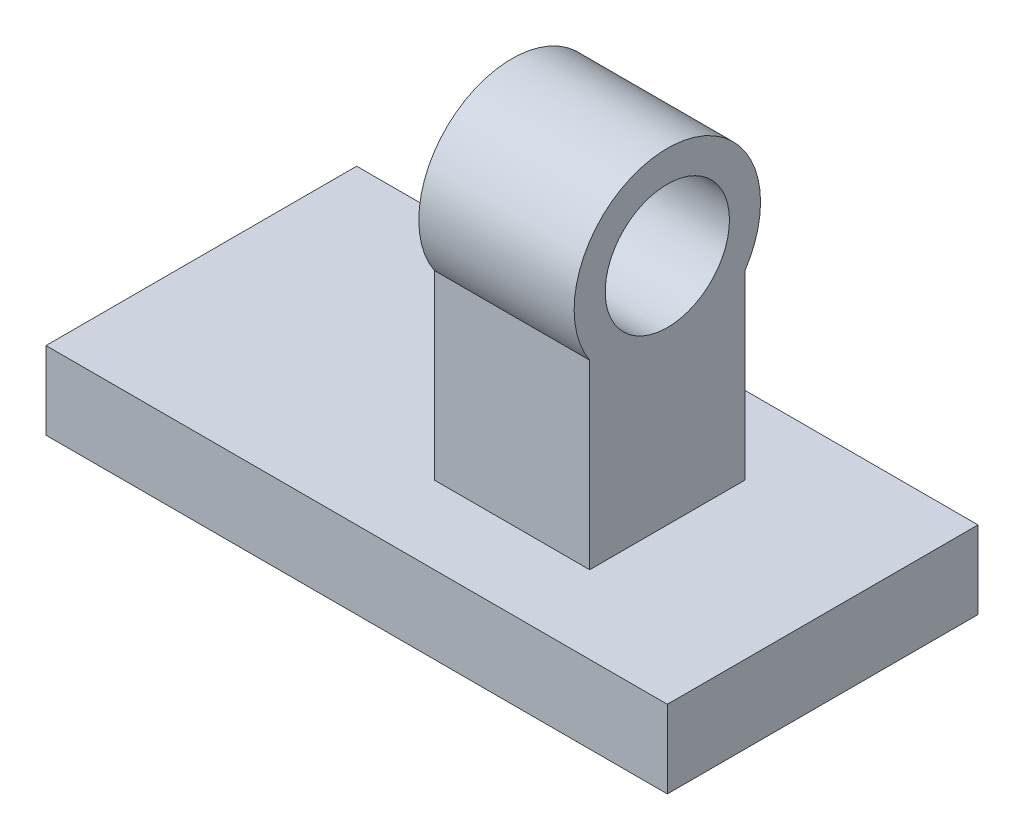
from build123d import *

# Parameters (mm, degrees)
LINKFRAME_R         = 40
BOSS_EXTRUDE1_DEPTH = 100
EXTENDEDPRESS_W     = 200
EXTENDEDPRESS_H     = 50
BOSS_EXTRUDE2_DEPTH = 200


with BuildPart() as part:
    # LinkFrame → Boss-Extrude1 (new body)
    with BuildSketch(Plane(origin=(0, 0, 0), x_dir=(0, 0, -1), z_dir=(1, 0, 0))):
        with BuildLine():
            Line((316.746524862, -249.209808828), (316.746524862, -366.043560924))
            Line((316.746524862, -366.043560924), (366.746524862, -366.043560924))
            Line((366.746524862, -366.043560924), (366.746524862, -416.043560924))
            Line((366.746524862, -416.043560924), (166.746524862, -416.043560924))
            Line((166.746524862, -416.043560924), (166.746524862, -366.043560924))
            Line((166.746524862, -366.043560924), (216.746524862, -366.043560924))
            Line((216.746524862, -366.043560924), (216.746524862, -249.209808828))
            ThreePointArc((216.746524862, -249.209808828), (266.746524862, -156.043560924), (316.746524862, -249.209808828))
        make_face()
        with Locations((266.746524862, -216.043560924)):
            Circle(LINKFRAME_R, mode=Mode.SUBTRACT)
    extrude(amount=BOSS_EXTRUDE1_DEPTH)

    # ExtendedPress → Boss-Extrude2 (add, symmetric)
    with BuildSketch(Plane(origin=(0, 0, 0), x_dir=(0, 0, -1), z_dir=(1, 0, 0))):
        with Locations((266.746524862, -391.043560924)):
            Rectangle(EXTENDEDPRESS_W, EXTENDEDPRESS_H)
    extrude(amount=BOSS_EXTRUDE2_DEPTH, both=True)


solid = part.part
